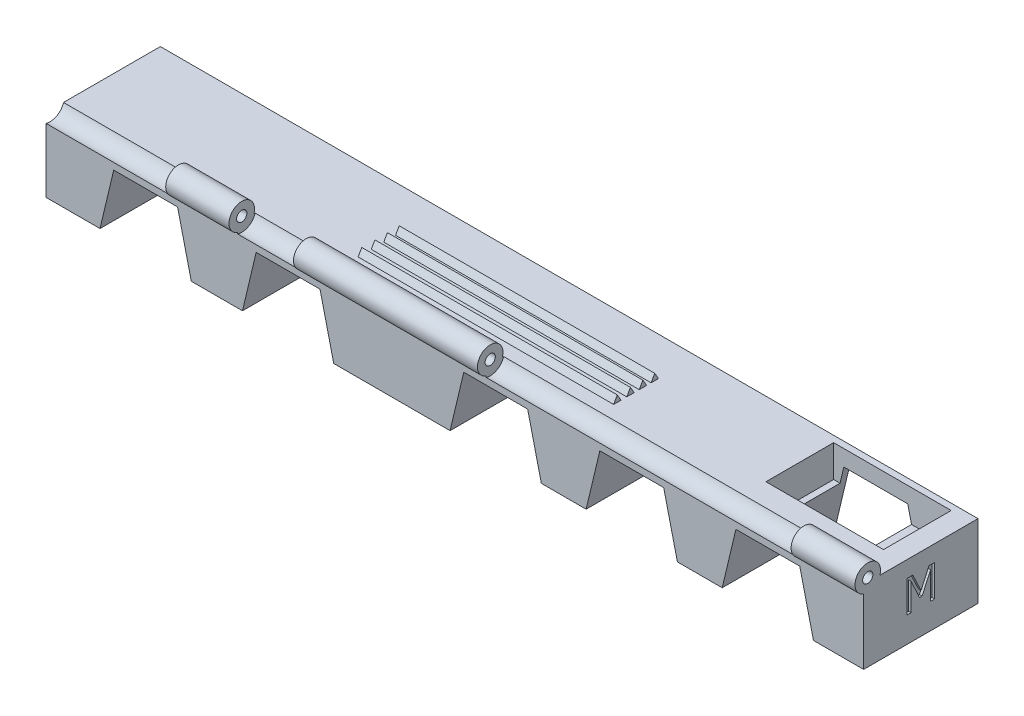
from build123d import *

# Parameters (mm, degrees)
SKETCH1_R                 = 7.62
BOSS_EXTRUDE3_DEPTH       = 127
CUT_EXTRUDE8_DEPTH        = 10.16
CUT_EXTRUDE8_DEPTH_BACK   = 20.828
SKETCH3_W                 = 3.81
SKETCH3_H                 = 18.722382306
SKETCH3_W_2               = 12.7
SKETCH5_W                 = 3.81
SKETCH5_H                 = 18.722382306
CUT_EXTRUDE9_DEPTH        = 36.576
SKETCH6_W                 = 12.7
SKETCH6_H                 = 18.722382306
SKETCH6_W_2               = 3.81
SKETCH6_W_3               = 71.12
CUT_EXTRUDE11_DEPTH       = 36.576
CUT_EXTRUDE12_DEPTH       = 20.32
CUT_EXTRUDE12_DEPTH_BACK  = 33.02
CUT_EXTRUDE21_DEPTH       = 20.32
CUT_EXTRUDE21_DEPTH_BACK  = 33.02
CUT_EXTRUDE23_DEPTH       = 20.32
CUT_EXTRUDE23_DEPTH_BACK  = 33.02
CUT_EXTRUDE26_DEPTH       = 20.32
CUT_EXTRUDE26_DEPTH_BACK  = 33.02
CUT_EXTRUDE27_DEPTH       = 20.32
CUT_EXTRUDE27_DEPTH_BACK  = 33.02
SCALE1_SCALE              = 1.3
CUT_EXTRUDE28_START       = -154.94
SKETCH26_R                = 13.065490037
CUT_EXTRUDE28_DEPTH       = 154.94
SKETCH27_W                = 13.208
SKETCH27_H                = 4.731500073
BOSS_EXTRUDE4_DEPTH       = 165.1
CUT_EXTRUDE29_DEPTH       = 14.224
CUT_EXTRUDE29_DEPTH_BACK  = 203.962
SKETCH28_W                = 13.208
SKETCH28_H                = 4.731500073
SKETCH29_W                = 150.317302473
SKETCH29_H                = 24.765
BOSS_EXTRUDE5_DEPTH       = 33.02
SKETCH30_W                = 165.1
SKETCH30_H                = 8.255
CUT_EXTRUDE30_DEPTH       = 33.02
SKETCH31_W                = 13.97
SKETCH31_H                = 16.51
CUT_EXTRUDE31_DEPTH       = 204.216
CUT_EXTRUDE32_DEPTH       = 204.216
CUT_EXTRUDE33_DEPTH       = 204.216
BOSS_EXTRUDE6_DEPTH       = 19.05
BOSS_EXTRUDE7_DEPTH       = 165.1
CUT_EXTRUDE34_DEPTH       = 165.1
CUT_EXTRUDE45_DEPTH       = 19.558
CUT_EXTRUDE45_DEPTH_BACK  = 50.8
SKETCH46_R                = 6.3627
CUT_EXTRUDE46_DEPTH       = 55.88
CUT_EXTRUDE46_DEPTH_BACK  = 50.8
SKETCH47_R                = 6.3627
CUT_EXTRUDE47_DEPTH       = 11.43
CUT_EXTRUDE47_DEPTH_BACK  = 67.818
CUT_EXTRUDE48_DEPTH       = 9.652
CUT_EXTRUDE48_DEPTH_BACK  = 67.31
SKETCH50_R                = 3.9878
SKETCH51_W                = 2.128397358
SKETCH51_H                = 21.339200712
CUT_EXTRUDE49_DEPTH       = 67.31
SKETCH52_R                = 6.604
CUT_EXTRUDE50_DEPTH       = 50.8
CUT_EXTRUDE51_START       = -50.8
SKETCH53_R                = 6.604
CUT_EXTRUDE51_DEPTH       = 50.8
BOSS_EXTRUDE8_DEPTH       = 19.05
CUT_EXTRUDE52_DEPTH       = 19.05
BOSS_EXTRUDE9_DEPTH       = 19.05
CUT_EXTRUDE53_DEPTH       = 19.05
SKETCH58_W                = 0.5461
SKETCH58_H                = 19.05
CUT_EXTRUDE54_DEPTH       = 45.974
CUT_EXTRUDE55_DEPTH       = 45.974
BOSS_EXTRUDE10_DEPTH      = 19.05
SKETCH61_W                = 0.3429
SKETCH61_H                = 19.05
CUT_EXTRUDE56_DEPTH       = 37.338
CUT_EXTRUDE60_DEPTH       = 8.89
CUT_EXTRUDE60_DEPTH_BACK  = 38.1
SKETCH75_R                = 3.175
CUT_EXTRUDE61_DEPTH       = 12.7
CUT_EXTRUDE61_DEPTH_BACK  = 67.31
SKETCH81_R                = 2.499995
BOSS_EXTRUDE11_DEPTH      = 9.398
BOSS_EXTRUDE12_START      = -9.398
BOSS_EXTRUDE12_DEPTH      = 9.398
CUT_EXTRUDE62_DEPTH       = 5.842
CUT_EXTRUDE62_DEPTH_BACK  = 24.892
BOSS_EXTRUDE13_DEPTH      = 19.05
CUT_EXTRUDE64_DEPTH       = 19.05
BOSS_EXTRUDE15_DEPTH      = 19.05
CUT_EXTRUDE65_DEPTH       = 19.05
BOSS_EXTRUDE16_DEPTH      = 19.05
CUT_EXTRUDE66_DEPTH       = 19.05
BOSS_EXTRUDE17_DEPTH      = 19.05
CUT_EXTRUDE67_DEPTH       = 19.05
BOSS_EXTRUDE18_DEPTH      = 19.05
CUT_EXTRUDE68_DEPTH       = 19.05
BOSS_EXTRUDE19_DEPTH      = 19.05
CUT_EXTRUDE69_DEPTH       = 19.05
BOSS_EXTRUDE20_DEPTH      = 19.05
CUT_EXTRUDE70_DEPTH       = 19.05
BOSS_EXTRUDE21_DEPTH      = 19.05
CUT_EXTRUDE71_DEPTH       = 10.668
CUT_EXTRUDE71_DEPTH_BACK  = 35.306
SKETCH105_R               = 2.50000008
CUT_EXTRUDE72_DEPTH       = 19.812
CUT_EXTRUDE72_DEPTH_BACK  = 56.388
SKETCH106_W               = 0.381
SKETCH106_H               = 30.850817133
SKETCH108_W               = 19.05
SKETCH108_H               = 3.81
BOSS_EXTRUDE22_DEPTH      = 162.56
SKETCH109_W               = 19.05
SKETCH109_H               = 40.733446347
CUT_EXTRUDE73_DEPTH       = 162.56
SKETCH110_R               = 3.425685186
SKETCH110_R_2             = 3.853308442
BOSS_EXTRUDE23_DEPTH      = 19.05
SKETCH111_W               = 162.56
SKETCH111_H               = 2.54
CUT_EXTRUDE76_DEPTH       = 19.05
SKETCH112_R               = 1.6002
SKETCH112_R_2             = 0.8128
BOSS_EXTRUDE25_DEPTH      = 162.56
CUT_EXTRUDE83_DEPTH       = 19.558
CUT_EXTRUDE83_DEPTH_BACK  = 29.21
SKETCH115_W               = 55.88
SKETCH115_H               = 2.413
SKETCH118_W               = 55.88
SKETCH118_H               = 0.565603497
CUT_EXTRUDE84_DEPTH       = 29.21
SKETCH119_R               = 1.778
CUT_EXTRUDE85_DEPTH       = 57.912
CUT_EXTRUDE86_START       = 65.278
SKETCH120_R               = 1.778
CUT_EXTRUDE86_DEPTH       = 65.278
BOSS_EXTRUDE26_DEPTH      = 3.6817427
SKETCH124_W               = 0.0012573
SKETCH124_H               = 16.51
BOSS_EXTRUDE27_DEPTH      = 162.56
CUT_EXTRUDE87_DEPTH       = 162.56
BOSS_EXTRUDE29_DEPTH      = 50.8
FILLET5_R                 = 0.762
SKETCH131_W               = 0.398403583
SKETCH131_H               = 0.613592462
CUT_EXTRUDE88_DEPTH       = 50.8
BOSS_EXTRUDE30_DEPTH      = 50.8
SKETCH133_W               = 0.963005867
SKETCH133_H               = 0.762
CUT_EXTRUDE89_DEPTH       = 50.8
BOSS_EXTRUDE31_DEPTH      = 50.8
BOSS_EXTRUDE33_DEPTH      = 50.8
BOSS_EXTRUDE34_DEPTH      = 50.8
BOSS_EXTRUDE36_DEPTH      = 50.8
BOSS_EXTRUDE38_DEPTH      = 50.8
CUT_EXTRUDE90_DEPTH       = 50.8
BOSS_EXTRUDE40_DEPTH      = 50.8
CUT_EXTRUDE91_DEPTH       = 50.8
BOSS_EXTRUDE41_DEPTH      = 50.8
CUT_EXTRUDE92_DEPTH       = 50.8
CUT_EXTRUDE93_DEPTH       = 50.8
CUT_EXTRUDE94_DEPTH       = 50.8
BOSS_EXTRUDE42_DEPTH      = 50.8
CUT_EXTRUDE95_DEPTH       = 50.8
BOSS_EXTRUDE43_DEPTH      = 50.8
CUT_EXTRUDE96_DEPTH       = 50.8
SKETCH150_R               = 2.54
BOSS_EXTRUDE44_DEPTH      = 50.8
SKETCH151_R               = 1.27
CUT_EXTRUDE97_DEPTH       = 50.8
SKETCH152_R               = 2.794
CUT_EXTRUDE98_DEPTH       = 68.326
CUT_EXTRUDE99_START       = 58.928
SKETCH153_R               = 2.794
CUT_EXTRUDE99_DEPTH       = 58.928
SKETCH157_W               = 5.08
SKETCH157_H               = 12.7
CUT_EXTRUDE100_DEPTH      = 5.08
SKETCH158_R               = 1.7827949
SKETCH158_R_2             = 1.016
BOSS_EXTRUDE45_DEPTH      = 50.8
SKETCH159_W               = 162.56
SKETCH159_H               = 1.905
CUT_EXTRUDE101_DEPTH      = 29.21
BOSS_EXTRUDE47_DEPTH      = 55.88
BOSS_EXTRUDE47_DEPTH_BACK = 106.68
SKETCH162_R               = 1.016
SKETCH165_R               = 2.794
CUT_EXTRUDE104_DEPTH      = 25.527
SKETCH167_R               = 2.794
CUT_EXTRUDE105_DEPTH      = 12.827
CUT_EXTRUDE106_START      = -62.357
SKETCH171_R               = 2.794
CUT_EXTRUDE106_DEPTH      = 62.357
CUT_EXTRUDE108_DEPTH      = 6.35
BOSS_EXTRUDE48_DEPTH      = 13.462
CUT_EXTRUDE109_DEPTH      = 13.462
SKETCH177_W               = 7.62
SKETCH177_H               = 13.433519273
CUT_EXTRUDE110_DEPTH      = 6.35
SKETCH178_W               = 8.89
SKETCH178_H               = 14.703519273
BOSS_EXTRUDE50_DEPTH      = 7.366
SKETCH181_W               = 0.762
SKETCH181_H               = 13.433519273
CUT_EXTRUDE113_DEPTH      = 19.558
SKETCH183_W               = 8.382
SKETCH183_H               = 13.462
CUT_EXTRUDE115_DEPTH      = 6.35
CUT_EXTRUDE116_DEPTH      = 0.508
CUT_EXTRUDE117_DEPTH      = 0.508
SKETCH187_W               = 23.368
SKETCH187_H               = 13.462
CUT_EXTRUDE119_DEPTH      = 6.35


with BuildPart() as part:
    # Sketch1 → Boss-Extrude3 (new body)
    with BuildSketch(Plane(origin=(0, 0, 0), x_dir=(0, 0, -1), z_dir=(1, 0, 0))):
        with BuildLine():
            Line((0, 19.05), (0, 0))
            Line((0, 0), (25.4, 0))
            Line((25.4, 0), (25.4, 19.05))
            Line((25.4, 19.05), (17.78, 19.05))
            Line((17.78, 19.05), (17.78, 22.689615441))
            ThreePointArc((17.78, 22.689615441), (12.7, 41.411997747), (7.62, 22.689615441))
            Line((7.62, 22.689615441), (7.62, 19.05))
            Line((7.62, 19.05), (0, 19.05))
        make_face()
        with Locations((12.7, 31.361620795)):
            Circle(SKETCH1_R, mode=Mode.SUBTRACT)
    extrude(amount=BOSS_EXTRUDE3_DEPTH)

    # Sketch3 → Cut-Extrude8 (cut, two sides: drawn at the far end of the back side and taken through both)
    with BuildSketch(Plane.XY.offset(-7.62).offset(-CUT_EXTRUDE8_DEPTH_BACK)):
        with Locations((17.145, 32.050806594)):
            Rectangle(SKETCH3_W, SKETCH3_H)
        with Locations((6.35, 32.050806594)):
            Rectangle(SKETCH3_W_2, SKETCH3_H)
    extrude(amount=CUT_EXTRUDE8_DEPTH + CUT_EXTRUDE8_DEPTH_BACK, mode=Mode.SUBTRACT)

    # Sketch5 → Cut-Extrude9 (cut)
    with BuildSketch(Plane.XY):
        with Locations((23.495, 32.050806594)):
            Rectangle(SKETCH5_W, SKETCH5_H)
    extrude(amount=-CUT_EXTRUDE9_DEPTH, mode=Mode.SUBTRACT)

    # Sketch6 → Cut-Extrude11 (cut)
    with BuildSketch(Plane.XY):
        with Locations((120.65, 32.050806594)):
            Rectangle(SKETCH6_W, SKETCH6_H)
        with Locations((109.855, 32.050806594)):
            Rectangle(SKETCH6_W_2, SKETCH6_H)
        with Locations((103.505, 32.050806594)):
            Rectangle(SKETCH6_W_2, SKETCH6_H)
        with Locations((63.5, 32.050806594)):
            Rectangle(SKETCH6_W_3, SKETCH6_H)
    extrude(amount=-CUT_EXTRUDE11_DEPTH, mode=Mode.SUBTRACT)

    # Sketch7 → Cut-Extrude12 (cut, two sides: drawn at the far end of the back side and taken through both)
    with BuildSketch(Plane(origin=(0, 0, -17.78), x_dir=(-1, 0, 0), z_dir=(0, 0, -1)).offset(-CUT_EXTRUDE12_DEPTH_BACK)):
        Polygon((-116.586, 0), (-113.807281861, 15.758893664), (-108.211772717, 15.758893664), (-105.54672105, 0), align=None)
    extrude(amount=CUT_EXTRUDE12_DEPTH + CUT_EXTRUDE12_DEPTH_BACK, mode=Mode.SUBTRACT)

    # Sketch17 → Cut-Extrude21 (cut, two sides: drawn at the far end of the back side and taken through both)
    with BuildSketch(Plane.XY.offset(-CUT_EXTRUDE21_DEPTH_BACK)):
        Polygon((85.106525364, -0.117469901), (87.885243503, 15.641423763), (93.480752647, 15.641423763), (96.145804314, -0.117469901), align=None)
    extrude(amount=CUT_EXTRUDE21_DEPTH + CUT_EXTRUDE21_DEPTH_BACK, mode=Mode.SUBTRACT)

    # Sketch19 → Cut-Extrude23 (cut, two sides: drawn at the far end of the back side and taken through both)
    with BuildSketch(Plane.XY.offset(-CUT_EXTRUDE23_DEPTH_BACK)):
        Polygon((64.184734764, -0.117469901), (66.963452903, 15.641423763), (72.558962046, 15.641423763), (75.224013714, -0.117469901), align=None)
    extrude(amount=CUT_EXTRUDE23_DEPTH + CUT_EXTRUDE23_DEPTH_BACK, mode=Mode.SUBTRACT)

    # Sketch22 → Cut-Extrude26 (cut, two sides: drawn at the far end of the back side and taken through both)
    with BuildSketch(Plane.XY.offset(-CUT_EXTRUDE26_DEPTH_BACK)):
        Polygon((32.802048863, -0.117469901), (35.580767002, 15.641423763), (41.176276145, 15.641423763), (43.841327813, -0.117469901), align=None)
    extrude(amount=CUT_EXTRUDE26_DEPTH + CUT_EXTRUDE26_DEPTH_BACK, mode=Mode.SUBTRACT)

    # Sketch23 → Cut-Extrude27 (cut, two sides: drawn at the far end of the back side and taken through both)
    with BuildSketch(Plane.XY.offset(-CUT_EXTRUDE27_DEPTH_BACK)):
        Polygon((11.350592677, -0.117469901), (14.129310816, 15.641423763), (19.72481996, 15.641423763), (22.389871627, -0.117469901), align=None)
    extrude(amount=CUT_EXTRUDE27_DEPTH + CUT_EXTRUDE27_DEPTH_BACK, mode=Mode.SUBTRACT)


with BuildPart() as part_1:
    # Scale1: scaled about (62.883509837, 12.209293534, -12.7)
    add(part.part.scale(SCALE1_SCALE).moved(Location((-18.865052951, -3.66278806, 3.81))))

    # Sketch26 → Cut-Extrude28 (cut)
    with BuildSketch(Plane(origin=(129.724947049, 0, 0), x_dir=(0, 0, -1), z_dir=(1, 0, 0)).offset(CUT_EXTRUDE28_START)):
        with Locations((12.7, 37.107318973)):
            Circle(SKETCH26_R)
    extrude(amount=CUT_EXTRUDE28_DEPTH, mode=Mode.SUBTRACT)

    # Sketch27 → Boss-Extrude4 (add)
    with BuildSketch(Plane(origin=(146.234947049, 0, 0), x_dir=(0, 0, -1), z_dir=(1, 0, 0))):
        with Locations((12.7, 23.467961976)):
            Rectangle(SKETCH27_W, SKETCH27_H)
    extrude(amount=-BOSS_EXTRUDE4_DEPTH)

    # Sketch28 → Cut-Extrude29 (cut, two sides: drawn at the far end of the back side and taken through both)
    with BuildSketch(Plane.ZY.offset(18.865052951).offset(-CUT_EXTRUDE29_DEPTH_BACK)):
        with Locations((-12.7, 23.467961976)):
            Rectangle(SKETCH28_W, SKETCH28_H)
    extrude(amount=CUT_EXTRUDE29_DEPTH + CUT_EXTRUDE29_DEPTH_BACK, mode=Mode.SUBTRACT)

    # Sketch29 → Boss-Extrude5 (add)
    with BuildSketch(Plane.XY.offset(3.81)):
        with Locations((71.076295812, 8.71971194)):
            Rectangle(SKETCH29_W, SKETCH29_H)
    extrude(amount=-BOSS_EXTRUDE5_DEPTH)

    # Sketch30 → Cut-Extrude30 (cut)
    with BuildSketch(Plane(origin=(0, 0, -29.21), x_dir=(-1, 0, 0), z_dir=(0, 0, -1))):
        with Locations((-63.684947049, 16.97471194)):
            Rectangle(SKETCH30_W, SKETCH30_H)
    extrude(amount=-CUT_EXTRUDE30_DEPTH, mode=Mode.SUBTRACT)

    # Sketch31 → Cut-Extrude31 (cut)
    with BuildSketch(Plane.ZY.offset(18.865052951)):
        with Locations((-3.175, 4.59221194)):
            Rectangle(SKETCH31_W, SKETCH31_H)
    extrude(amount=-CUT_EXTRUDE31_DEPTH, mode=Mode.SUBTRACT)

    # Sketch33 → Cut-Extrude32 (cut)
    with BuildSketch(Plane(origin=(0, 0, -29.21), x_dir=(-1, 0, 0), z_dir=(0, 0, -1))):
        Polygon((-104.959947049, 9.67221194), (-108.134947049, -3.66278806), (-89.084947049, -3.66278806), (-92.259947049, 9.67221194), align=None)
        Polygon((-6.534947049, 9.67221194), (-9.709947049, -3.66278806), (9.340052951, -3.66278806), (6.165052951, 9.67221194), align=None)
        Polygon((-35.109947049, 9.67221194), (-38.284947049, -3.66278806), (-19.234947049, -3.66278806), (-22.409947049, 9.67221194), align=None)
        Polygon((-76.384947049, 9.67221194), (-79.559947049, -3.66278806), (-60.509947049, -3.66278806), (-63.684947049, 9.67221194), align=None)
    extrude(amount=-CUT_EXTRUDE32_DEPTH, mode=Mode.SUBTRACT)

    # Sketch34 → Cut-Extrude33 (cut)
    with BuildSketch(Plane.XY.offset(-10.16)):
        Polygon((136.709947049, -3.66278806), (133.534947049, 9.67221194), (120.834947049, 9.67221194), (117.659947049, -3.66278806), align=None)
    extrude(amount=-CUT_EXTRUDE33_DEPTH, mode=Mode.SUBTRACT)

    # Sketch35 → Boss-Extrude6 (add)
    with BuildSketch(Plane.XY.offset(-10.16)):
        Polygon((-18.865052951, 12.84721194), (-18.865052951, 15.38721194), (146.276628632, 15.38721194), (146.234947049, 12.84721194), align=None)
    extrude(amount=-BOSS_EXTRUDE6_DEPTH)

    # Sketch44 → Boss-Extrude7 (add)
    with BuildSketch(Plane(origin=(146.234947049, 0, 0), x_dir=(0, 0, -1), z_dir=(1, 0, 0))):
        with BuildLine():
            ThreePointArc((26.035, 19.19721194), (17.676953686, 25.221350882), (14.605, 15.38721194))
            Line((14.605, 15.38721194), (24.765, 15.38721194))
            ThreePointArc((24.765, 15.38721194), (25.709138943, 17.189165625), (26.035, 19.19721194))
        make_face()
    extrude(amount=-BOSS_EXTRUDE7_DEPTH)

    # Sketch45 → Cut-Extrude34 (cut)
    with BuildSketch(Plane(origin=(146.234947049, 0, 0), x_dir=(0, 0, -1), z_dir=(1, 0, 0))):
        with BuildLine():
            ThreePointArc((19.685, 15.38721194), (22.379076836, 16.503135103), (23.495, 19.19721194))
            ThreePointArc((23.495, 19.19721194), (16.990923164, 21.891288776), (19.685, 15.38721194))
        make_face()
    extrude(amount=-CUT_EXTRUDE34_DEPTH, mode=Mode.SUBTRACT)

    # Sketch46 → Cut-Extrude45 (cut, two sides: drawn at the far end of the back side and taken through both)
    with BuildSketch(Plane(origin=(146.234947049, 0, 0), x_dir=(0, 0, -1), z_dir=(1, 0, 0)).offset(-CUT_EXTRUDE45_DEPTH_BACK)):
        with Locations((19.685, 19.19721194)):
            Circle(SKETCH46_R)
    extrude(amount=CUT_EXTRUDE45_DEPTH + CUT_EXTRUDE45_DEPTH_BACK, mode=Mode.SUBTRACT)

    # Sketch47 → Cut-Extrude46 (cut, two sides: drawn at the far end of the back side and taken through both)
    with BuildSketch(Plane.ZY.offset(18.865052951).offset(-CUT_EXTRUDE46_DEPTH_BACK)):
        with Locations((-19.685, 19.19721194)):
            Circle(SKETCH47_R)
    extrude(amount=CUT_EXTRUDE46_DEPTH + CUT_EXTRUDE46_DEPTH_BACK, mode=Mode.SUBTRACT)

    # Sketch49 → Cut-Extrude47 (cut, two sides: drawn at the far end of the back side and taken through both)
    with BuildSketch(Plane(origin=(95.434947049, 0, 0), x_dir=(0, 0, -1), z_dir=(1, 0, 0)).offset(-CUT_EXTRUDE47_DEPTH_BACK)):
        with BuildLine():
            ThreePointArc((26.035, 19.19721194), (17.676953686, 25.221350882), (14.605, 15.38721194))
            Line((14.605, 15.38721194), (14.764671861, 15.38721194))
            ThreePointArc((14.764671861, 15.38721194), (17.671728162, 25.085544939), (25.908, 19.19721194))
            ThreePointArc((25.908, 19.19721194), (25.573332999, 17.183940102), (24.605328139, 15.38721194))
            Line((24.605328139, 15.38721194), (24.765, 15.38721194))
            ThreePointArc((24.765, 15.38721194), (25.709138943, 17.189165625), (26.035, 19.19721194))
        make_face()
    extrude(amount=CUT_EXTRUDE47_DEPTH + CUT_EXTRUDE47_DEPTH_BACK, mode=Mode.SUBTRACT)

    # Sketch50 → Cut-Extrude48 (cut, two sides: drawn at the far end of the back side and taken through both)
    with BuildSketch(Plane(origin=(95.434947049, 0, 0), x_dir=(0, 0, -1), z_dir=(1, 0, 0)).offset(-CUT_EXTRUDE48_DEPTH_BACK)):
        with Locations((19.685, 19.19721194)):
            Circle(SKETCH50_R)
    extrude(amount=CUT_EXTRUDE48_DEPTH + CUT_EXTRUDE48_DEPTH_BACK, mode=Mode.SUBTRACT)

    # Sketch51 → Cut-Extrude49 (cut)
    with BuildSketch(Plane(origin=(0, 0, -29.21), x_dir=(-1, 0, 0), z_dir=(0, 0, -1))):
        with Locations((-147.299145728, 7.006812296)):
            Rectangle(SKETCH51_W, SKETCH51_H)
    extrude(amount=-CUT_EXTRUDE49_DEPTH, mode=Mode.SUBTRACT)

    # Sketch52 → Cut-Extrude50 (cut)
    with BuildSketch(Plane(origin=(146.234947049, 0, 0), x_dir=(0, 0, -1), z_dir=(1, 0, 0))):
        with Locations((19.685, 19.19721194)):
            Circle(SKETCH52_R)
    extrude(amount=-CUT_EXTRUDE50_DEPTH, mode=Mode.SUBTRACT)

    # Sketch53 → Cut-Extrude51 (cut)
    with BuildSketch(Plane.ZY.offset(18.865052951).offset(CUT_EXTRUDE51_START)):
        with Locations((-19.685, 19.19721194)):
            Circle(SKETCH53_R)
    extrude(amount=CUT_EXTRUDE51_DEPTH, mode=Mode.SUBTRACT)

    # Sketch54 → Boss-Extrude8 (add)
    with BuildSketch(Plane.XY.offset(-10.16)):
        Polygon((-9.340052951, -3.66278806), (-7.752552951, -3.66278806), (-4.577552951, 9.67221194), (-6.165052951, 9.67221194), align=None)
    extrude(amount=-BOSS_EXTRUDE8_DEPTH)

    # Sketch55 → Cut-Extrude52 (cut)
    with BuildSketch(Plane.XY.offset(-10.16)):
        Polygon((8.122447049, 9.67221194), (6.534947049, 9.67221194), (9.709947049, -3.66278806), (11.297447049, -3.66278806), align=None)
    extrude(amount=-CUT_EXTRUDE52_DEPTH, mode=Mode.SUBTRACT)

    # Sketch56 → Boss-Extrude9 (add)
    with BuildSketch(Plane.XY.offset(-10.16)):
        Polygon((19.234947049, -3.66278806), (20.822447049, -3.66278806), (23.997447049, 9.67221194), (22.409947049, 9.67221194), align=None)
        Polygon((60.509947049, -3.66278806), (62.097447049, -3.66278806), (65.272447049, 9.67221194), (63.684947049, 9.67221194), align=None)
        Polygon((136.709947049, -3.66278806), (135.122447049, -3.66278806), (131.947447049, 9.67221194), (133.534947049, 9.67221194), align=None)
    extrude(amount=-BOSS_EXTRUDE9_DEPTH)

    # Sketch57 → Cut-Extrude53 (cut)
    with BuildSketch(Plane.XY.offset(-10.16)):
        Polygon((35.109947049, 9.67221194), (36.697447049, 9.67221194), (39.872447049, -3.66278806), (38.284947049, -3.66278806), align=None)
        Polygon((79.559947049, -3.66278806), (81.147447049, -3.66278806), (77.972447049, 9.67221194), (76.384947049, 9.67221194), align=None)
        Polygon((117.659947049, -3.66278806), (116.072447049, -3.66278806), (119.247447049, 9.67221194), (120.834947049, 9.67221194), align=None)
    extrude(amount=-CUT_EXTRUDE53_DEPTH, mode=Mode.SUBTRACT)

    # Sketch58 → Cut-Extrude54 (cut)
    with BuildSketch(Plane(origin=(0, 0, -29.21), x_dir=(-1, 0, 0), z_dir=(0, 0, -1))):
        with Locations((18.592002951, 5.86221194)):
            Rectangle(SKETCH58_W, SKETCH58_H)
        with Locations((-145.961897049, 5.86221194)):
            Rectangle(SKETCH58_W, SKETCH58_H)
    extrude(amount=-CUT_EXTRUDE54_DEPTH, mode=Mode.SUBTRACT)

    # Sketch59 → Cut-Extrude55 (cut)
    with BuildSketch(Plane.XY.offset(-10.16)):
        Polygon((-7.752552951, -3.66278806), (-8.324052951, -3.66278806), (-5.149052951, 9.67221194), (-4.577552951, 9.67221194), align=None)
        Polygon((23.997447049, 9.67221194), (23.425947049, 9.67221194), (20.250947049, -3.66278806), (20.822447049, -3.66278806), align=None)
        Polygon((62.097447049, -3.66278806), (61.525947049, -3.66278806), (64.700947049, 9.67221194), (65.272447049, 9.67221194), align=None)
        Polygon((135.122447049, -3.66278806), (135.693947049, -3.66278806), (132.518947049, 9.67221194), (131.947447049, 9.67221194), align=None)
    extrude(amount=-CUT_EXTRUDE55_DEPTH, mode=Mode.SUBTRACT)

    # Sketch60 → Boss-Extrude10 (add)
    with BuildSketch(Plane.XY.offset(-10.16)):
        Polygon((8.122447049, 9.67221194), (7.550947049, 9.67221194), (10.725947049, -3.66278806), (11.297447049, -3.66278806), align=None)
        Polygon((36.697447049, 9.67221194), (36.125947049, 9.67221194), (39.300947049, -3.66278806), (39.872447049, -3.66278806), align=None)
        Polygon((77.972447049, 9.67221194), (77.400947049, 9.67221194), (80.575947049, -3.66278806), (81.147447049, -3.66278806), align=None)
        Polygon((116.072447049, -3.66278806), (116.643947049, -3.66278806), (119.818947049, 9.67221194), (119.247447049, 9.67221194), align=None)
    extrude(amount=-BOSS_EXTRUDE10_DEPTH)

    # Sketch61 → Cut-Extrude56 (cut)
    with BuildSketch(Plane.XY.offset(-10.16)):
        with Locations((145.517397049, 5.86221194)):
            Rectangle(SKETCH61_W, SKETCH61_H)
        with Locations((-18.147502951, 5.86221194)):
            Rectangle(SKETCH61_W, SKETCH61_H)
    extrude(amount=-CUT_EXTRUDE56_DEPTH, mode=Mode.SUBTRACT)

    # Sketch75 → Cut-Extrude60 (cut, two sides: drawn at the far end of the back side and taken through both)
    with BuildSketch(Plane(origin=(0, -3.66278806, 0), x_dir=(-1, 0, 0), z_dir=(0, -1, 0)).offset(-CUT_EXTRUDE60_DEPTH_BACK)):
        with Locations((13.043301181, 19.685)):
            Circle(SKETCH75_R)
    extrude(amount=CUT_EXTRUDE60_DEPTH + CUT_EXTRUDE60_DEPTH_BACK, mode=Mode.SUBTRACT)

    # Sketch81 → Cut-Extrude61 (cut, two sides: drawn at the far end of the back side and taken through both)
    with BuildSketch(Plane(origin=(0, -3.66278806, 0), x_dir=(-1, 0, 0), z_dir=(0, -1, 0)).offset(-CUT_EXTRUDE61_DEPTH_BACK)):
        with Locations((13.043301181, 19.685)):
            Circle(SKETCH81_R)
        with Locations((-140.413195279, 19.685)):
            Circle(SKETCH81_R)
    extrude(amount=CUT_EXTRUDE61_DEPTH + CUT_EXTRUDE61_DEPTH_BACK, mode=Mode.SUBTRACT)

    # Sketch85 → Boss-Extrude11 (add)
    with BuildSketch(Plane(origin=(145.345947049, 0, 0), x_dir=(0, 0, -1), z_dir=(1, 0, 0))):
        with BuildLine():
            Line((14.290862812, 15.38721194), (10.16, 15.38721194))
            Line((10.16, 15.38721194), (10.16, -3.66278806))
            Line((10.16, -3.66278806), (29.21, -3.66278806))
            Line((29.21, -3.66278806), (29.21, 15.38721194))
            Line((29.21, 15.38721194), (25.079137188, 15.38721194))
            ThreePointArc((25.079137188, 15.38721194), (19.685, 12.59321194), (14.290862812, 15.38721194))
        make_face()
    extrude(amount=-BOSS_EXTRUDE11_DEPTH)

    # Sketch86 → Boss-Extrude12 (add)
    with BuildSketch(Plane.ZY.offset(17.976052951).offset(BOSS_EXTRUDE12_START)):
        with BuildLine():
            Line((-25.079137188, 15.38721194), (-29.21, 15.38721194))
            Line((-29.21, 15.38721194), (-29.21, -3.66278806))
            Line((-29.21, -3.66278806), (-10.16, -3.66278806))
            Line((-10.16, -3.66278806), (-10.16, 15.38721194))
            Line((-10.16, 15.38721194), (-14.290862812, 15.38721194))
            ThreePointArc((-14.290862812, 15.38721194), (-19.685, 12.59321194), (-25.079137188, 15.38721194))
        make_face()
    extrude(amount=BOSS_EXTRUDE12_DEPTH)

    # Sketch87 → Cut-Extrude62 (cut, two sides: drawn at the far end of the back side and taken through both)
    with BuildSketch(Plane.XY.offset(-10.16).offset(-CUT_EXTRUDE62_DEPTH_BACK)):
        Polygon((116.643947049, -3.66278806), (119.818947049, 9.67221194), (119.564947049, 9.67221194), (116.389947049, -3.66278806), align=None)
    extrude(amount=CUT_EXTRUDE62_DEPTH + CUT_EXTRUDE62_DEPTH_BACK, mode=Mode.SUBTRACT)

    # Sketch88 → Boss-Extrude13 (add)
    with BuildSketch(Plane.XY.offset(-10.16)):
        Polygon((135.693947049, -3.66278806), (132.518947049, 9.67221194), (132.264947049, 9.67221194), (135.439947049, -3.66278806), align=None)
    extrude(amount=-BOSS_EXTRUDE13_DEPTH)

    # Sketch89 → Cut-Extrude64 (cut)
    with BuildSketch(Plane.XY.offset(-10.16)):
        Polygon((77.400947049, 9.67221194), (80.575947049, -3.66278806), (80.829947049, -3.66278806), (77.654947049, 9.67221194), align=None)
    extrude(amount=-CUT_EXTRUDE64_DEPTH, mode=Mode.SUBTRACT)

    # Sketch91 → Boss-Extrude15 (add)
    with BuildSketch(Plane.XY.offset(-10.16)):
        Polygon((61.525947049, -3.66278806), (64.700947049, 9.67221194), (64.954947049, 9.67221194), (61.779947049, -3.66278806), align=None)
    extrude(amount=-BOSS_EXTRUDE15_DEPTH)

    # Sketch92 → Cut-Extrude65 (cut)
    with BuildSketch(Plane.XY.offset(-10.16)):
        Polygon((80.829947049, -3.66278806), (81.083947049, -3.66278806), (77.908947049, 9.67221194), (77.654947049, 9.67221194), align=None)
    extrude(amount=-CUT_EXTRUDE65_DEPTH, mode=Mode.SUBTRACT)

    # Sketch93 → Boss-Extrude16 (add)
    with BuildSketch(Plane.XY.offset(-10.16)):
        Polygon((64.954947049, 9.67221194), (61.779947049, -3.66278806), (62.033947049, -3.66278806), (65.208947049, 9.67221194), align=None)
    extrude(amount=-BOSS_EXTRUDE16_DEPTH)

    # Sketch94 → Cut-Extrude66 (cut)
    with BuildSketch(Plane.XY.offset(-10.16)):
        Polygon((108.134947049, -3.66278806), (104.959947049, 9.67221194), (105.213947049, 9.67221194), (108.388947049, -3.66278806), align=None)
    extrude(amount=-CUT_EXTRUDE66_DEPTH, mode=Mode.SUBTRACT)

    # Sketch95 → Boss-Extrude17 (add)
    with BuildSketch(Plane.XY.offset(-10.16)):
        Polygon((92.259947049, 9.67221194), (92.513947049, 9.67221194), (89.338947049, -3.66278806), (89.084947049, -3.66278806), align=None)
    extrude(amount=-BOSS_EXTRUDE17_DEPTH)

    # Sketch96 → Cut-Extrude67 (cut)
    with BuildSketch(Plane.XY.offset(-10.16)):
        Polygon((81.083947049, -3.66278806), (81.337947049, -3.66278806), (78.162947049, 9.67221194), (77.908947049, 9.67221194), align=None)
    extrude(amount=-CUT_EXTRUDE67_DEPTH, mode=Mode.SUBTRACT)

    # Sketch97 → Boss-Extrude18 (add)
    with BuildSketch(Plane.XY.offset(-10.16)):
        Polygon((62.033947049, -3.66278806), (65.208947049, 9.67221194), (65.462947049, 9.67221194), (62.287947049, -3.66278806), align=None)
    extrude(amount=-BOSS_EXTRUDE18_DEPTH)

    # Sketch98 → Cut-Extrude68 (cut)
    with BuildSketch(Plane.XY.offset(-10.16)):
        Polygon((39.300947049, -3.66278806), (39.808947049, -3.66278806), (36.633947049, 9.67221194), (36.125947049, 9.67221194), align=None)
    extrude(amount=-CUT_EXTRUDE68_DEPTH, mode=Mode.SUBTRACT)

    # Sketch99 → Boss-Extrude19 (add)
    with BuildSketch(Plane.XY.offset(-10.16)):
        Polygon((20.250947049, -3.66278806), (20.758947049, -3.66278806), (23.933947049, 9.67221194), (23.425947049, 9.67221194), align=None)
    extrude(amount=-BOSS_EXTRUDE19_DEPTH)

    # Sketch100 → Cut-Extrude69 (cut)
    with BuildSketch(Plane.XY.offset(-10.16)):
        Polygon((39.808947049, -3.66278806), (36.633947049, 9.67221194), (36.887947049, 9.67221194), (40.062947049, -3.66278806), align=None)
    extrude(amount=-CUT_EXTRUDE69_DEPTH, mode=Mode.SUBTRACT)

    # Sketch101 → Boss-Extrude20 (add)
    with BuildSketch(Plane.XY.offset(-10.16)):
        Polygon((20.758947049, -3.66278806), (21.012947049, -3.66278806), (24.187947049, 9.67221194), (23.933947049, 9.67221194), align=None)
    extrude(amount=-BOSS_EXTRUDE20_DEPTH)

    # Sketch102 → Cut-Extrude70 (cut)
    with BuildSketch(Plane.XY.offset(-10.16)):
        Polygon((10.725947049, -3.66278806), (11.741947049, -3.66278806), (8.566947049, 9.67221194), (7.550947049, 9.67221194), align=None)
    extrude(amount=-CUT_EXTRUDE70_DEPTH, mode=Mode.SUBTRACT)

    # Sketch103 → Boss-Extrude21 (add)
    with BuildSketch(Plane.XY.offset(-10.16)):
        Polygon((-8.324052951, -3.66278806), (-5.149052951, 9.67221194), (-4.133052951, 9.67221194), (-7.308052951, -3.66278806), align=None)
    extrude(amount=-BOSS_EXTRUDE21_DEPTH)

    # Sketch105 → Cut-Extrude71 (cut, two sides: drawn at the far end of the back side and taken through both)
    with BuildSketch(Plane(origin=(0, -3.66278806, 0), x_dir=(-1, 0, 0), z_dir=(0, -1, 0)).offset(-CUT_EXTRUDE71_DEPTH_BACK)):
        with Locations((-140.392947049, 19.685)):
            Circle(SKETCH105_R)
        with Locations((13.023052951, 19.685)):
            Circle(SKETCH105_R)
    extrude(amount=CUT_EXTRUDE71_DEPTH + CUT_EXTRUDE71_DEPTH_BACK, mode=Mode.SUBTRACT)

    # Sketch106 → Cut-Extrude72 (cut, two sides: drawn at the far end of the back side and taken through both)
    with BuildSketch(Plane.XY.offset(-10.16).offset(-CUT_EXTRUDE72_DEPTH_BACK)):
        with Locations((145.155447049, 11.762620507)):
            Rectangle(SKETCH106_W, SKETCH106_H)
        with Locations((-17.785552951, 11.762620507)):
            Rectangle(SKETCH106_W, SKETCH106_H)
    extrude(amount=CUT_EXTRUDE72_DEPTH + CUT_EXTRUDE72_DEPTH_BACK, mode=Mode.SUBTRACT)

    # Sketch108 → Boss-Extrude22 (add)
    with BuildSketch(Plane.ZY.offset(17.595052951)):
        with Locations((-19.685, 13.48221194)):
            Rectangle(SKETCH108_W, SKETCH108_H)
    extrude(amount=-BOSS_EXTRUDE22_DEPTH)

    # Sketch109 → Cut-Extrude73 (cut)
    with BuildSketch(Plane(origin=(144.964947049, 0, 0), x_dir=(0, 0, -1), z_dir=(1, 0, 0))):
        with Locations((19.685, 35.753935114)):
            Rectangle(SKETCH109_W, SKETCH109_H)
    extrude(amount=-CUT_EXTRUDE73_DEPTH, mode=Mode.SUBTRACT)

    # Sketch110 → Boss-Extrude23 (add)
    with BuildSketch(Plane(origin=(0, -3.66278806, 0), x_dir=(-1, 0, 0), z_dir=(0, -1, 0))):
        with Locations((13.023052951, 19.685)):
            Circle(SKETCH110_R)
        with Locations((-140.392947049, 19.685)):
            Circle(SKETCH110_R_2)
    extrude(amount=-BOSS_EXTRUDE23_DEPTH)

    # Sketch111 → Cut-Extrude76 (cut)
    with BuildSketch(Plane.XY.offset(-10.16)):
        with Locations((63.684947049, 14.11721194)):
            Rectangle(SKETCH111_W, SKETCH111_H)
    extrude(amount=-CUT_EXTRUDE76_DEPTH, mode=Mode.SUBTRACT)

    # Sketch112 → Boss-Extrude25 (add)
    with BuildSketch(Plane(origin=(144.964947049, 0, 0), x_dir=(0, 0, -1), z_dir=(1, 0, 0))):
        with Locations((10.9728, 13.66001194)):
            Circle(SKETCH112_R)
        with Locations((10.9728, 13.66001194)):
            Circle(SKETCH112_R_2, mode=Mode.SUBTRACT)
    extrude(amount=-BOSS_EXTRUDE25_DEPTH)

    # Sketch115 → Cut-Extrude83 (cut, two sides: drawn at the far end of the back side and taken through both)
    with BuildSketch(Plane.XY.offset(-10.16).offset(-CUT_EXTRUDE83_DEPTH_BACK)):
        with Locations((10.344947049, 14.05371194)):
            Rectangle(SKETCH115_W, SKETCH115_H)
        with Locations((117.024947049, 14.05371194)):
            Rectangle(SKETCH115_W, SKETCH115_H)
    extrude(amount=CUT_EXTRUDE83_DEPTH + CUT_EXTRUDE83_DEPTH_BACK, mode=Mode.SUBTRACT)

    # Sketch118 → Cut-Extrude84 (cut)
    with BuildSketch(Plane(origin=(0, -3.66278806, 0), x_dir=(-1, 0, 0), z_dir=(0, -1, 0))):
        with Locations((-10.344947049, 9.877198252)):
            Rectangle(SKETCH118_W, SKETCH118_H)
        with Locations((-117.024947049, 9.877198252)):
            Rectangle(SKETCH118_W, SKETCH118_H)
    extrude(amount=-CUT_EXTRUDE84_DEPTH, mode=Mode.SUBTRACT)

    # Sketch119 → Cut-Extrude85 (cut)
    with BuildSketch(Plane.ZY.offset(-38.284947049)):
        with Locations((-10.9728, 13.66001194)):
            Circle(SKETCH119_R)
    extrude(amount=CUT_EXTRUDE85_DEPTH, mode=Mode.SUBTRACT)

    # Sketch120 → Cut-Extrude86 (cut)
    with BuildSketch(Plane(origin=(89.084947049, 0, 0), x_dir=(0, 0, -1), z_dir=(1, 0, 0)).offset(CUT_EXTRUDE86_START)):
        with Locations((10.9728, 13.66001194)):
            Circle(SKETCH120_R)
    extrude(amount=-CUT_EXTRUDE86_DEPTH, mode=Mode.SUBTRACT)

    # Sketch122 → Boss-Extrude26 (add)
    with BuildSketch(Plane(origin=(0, 0, -29.21), x_dir=(-1, 0, 0), z_dir=(0, 0, -1))):
        Polygon((-144.964947049, -3.66278806), (-135.439947049, -3.66278806), (-132.264947049, 9.67221194), (-119.564947049, 9.67221194), (-116.389947049, -3.66278806), (-108.388947049, -3.66278806), (-105.213947049, 9.67221194), (-92.513947049, 9.67221194), (-89.338947049, -3.66278806), (-81.337947049, -3.66278806), (-78.162947049, 9.67221194), (-65.462947049, 9.67221194), (-62.287947049, -3.66278806), (-40.062947049, -3.66278806), (-36.887947049, 9.67221194), (-24.187947049, 9.67221194), (-21.012947049, -3.66278806), (-11.741947049, -3.66278806), (-8.566947049, 9.67221194), (4.133052951, 9.67221194), (7.308052951, -3.66278806), (17.595052951, -3.66278806), (17.595052951, 12.84721194), (-144.964947049, 12.84721194), align=None)
    extrude(amount=BOSS_EXTRUDE26_DEPTH)

    # Sketch124 → Boss-Extrude27 (add)
    with BuildSketch(Plane(origin=(144.964947049, 0, 0), x_dir=(0, 0, -1), z_dir=(1, 0, 0))):
        with Locations((32.89237135, 4.59221194)):
            Rectangle(SKETCH124_W, SKETCH124_H)
    extrude(amount=-BOSS_EXTRUDE27_DEPTH)

    # Sketch125 → Cut-Extrude87 (cut)
    with BuildSketch(Plane.XY.offset(-10.16)):
        Polygon((135.439947049, -3.66278806), (132.264947049, 9.67221194), (119.564947049, 9.67221194), (116.389947049, -3.66278806), align=None)
        Polygon((108.388947049, -3.66278806), (105.213947049, 9.67221194), (92.513947049, 9.67221194), (89.338947049, -3.66278806), align=None)
        Polygon((81.337947049, -3.66278806), (78.162947049, 9.67221194), (65.462947049, 9.67221194), (62.287947049, -3.66278806), align=None)
        Polygon((24.187947049, 9.67221194), (36.887947049, 9.67221194), (40.062947049, -3.66278806), (21.012947049, -3.66278806), align=None)
        Polygon((11.741947049, -3.66278806), (8.566947049, 9.67221194), (-4.133052951, 9.67221194), (-7.308052951, -3.66278806), align=None)
    extrude(amount=-CUT_EXTRUDE87_DEPTH, mode=Mode.SUBTRACT)

    # Sketch129 → Boss-Extrude29 (add)
    with BuildSketch(Plane.ZY.offset(-38.284947049)):
        Polygon((-24.511, 14.11721194), (-25.244234842, 12.84721194), (-24.511, 12.84721194), align=None)
    extrude(amount=-BOSS_EXTRUDE29_DEPTH)

    # Fillet5
    fillet5_edges = [part_1.edges().sort_by_distance(p)[0] for p in [
        (63.684947049, 12.84721194, -24.511),
    ]]
    fillet(fillet5_edges, radius=FILLET5_R)

    # Sketch131 → Cut-Extrude88 (cut)
    with BuildSketch(Plane.ZY.offset(-38.284947049)):
        with Locations((-24.710201792, 13.916008171)):
            Rectangle(SKETCH131_W, SKETCH131_H)
    extrude(amount=-CUT_EXTRUDE88_DEPTH, mode=Mode.SUBTRACT)

    # Sketch132 → Boss-Extrude30 (add)
    with BuildSketch(Plane.ZY.offset(-38.284947049)):
        Polygon((-24.804293937, 13.60921194), (-24.511, 13.60921194), (-24.511, 14.11721194), (-24.765, 14.11721194), (-25.498234842, 12.84721194), (-25.244234842, 12.84721194), align=None)
    extrude(amount=-BOSS_EXTRUDE30_DEPTH)

    # Sketch133 → Cut-Extrude89 (cut)
    with BuildSketch(Plane.ZY.offset(-38.284947049)):
        with Locations((-24.029497067, 13.22821194)):
            Rectangle(SKETCH133_W, SKETCH133_H)
    extrude(amount=-CUT_EXTRUDE89_DEPTH, mode=Mode.SUBTRACT)

    # Sketch134 → Boss-Extrude31 (add)
    with BuildSketch(Plane.ZY.offset(-38.284947049)):
        Polygon((-23.777765158, 12.84721194), (-24.511, 14.11721194), (-24.511, 12.84721194), align=None)
    extrude(amount=-BOSS_EXTRUDE31_DEPTH)

    # Sketch135 → Boss-Extrude33 (add)
    with BuildSketch(Plane.ZY.offset(-38.284947049)):
        Polygon((-21.774530316, 14.11721194), (-22.507765158, 12.84721194), (-20.787295474, 12.84721194), (-21.520530316, 14.11721194), align=None)
    extrude(amount=-BOSS_EXTRUDE33_DEPTH)

    # Sketch136 → Boss-Extrude34 (add)
    with BuildSketch(Plane.ZY.offset(-38.284947049)):
        Polygon((-18.784060633, 14.11721194), (-19.517295474, 12.84721194), (-17.796825791, 12.84721194), (-18.530060633, 14.11721194), align=None)
    extrude(amount=-BOSS_EXTRUDE34_DEPTH)

    # Sketch137 → Boss-Extrude36 (add)
    with BuildSketch(Plane.ZY.offset(-38.284947049)):
        Polygon((-15.031590949, 14.11721194), (-15.764825791, 12.84721194), (-14.044356107, 12.84721194), (-14.777590949, 14.11721194), align=None)
    extrude(amount=-BOSS_EXTRUDE36_DEPTH)

    # Sketch138 → Boss-Extrude38 (add)
    with BuildSketch(Plane.ZY.offset(-38.284947049)):
        Polygon((-22.155530316, 14.11721194), (-21.901530316, 14.11721194), (-21.168295474, 12.84721194), (-22.507765158, 12.84721194), (-22.888765158, 12.84721194), align=None)
    extrude(amount=-BOSS_EXTRUDE38_DEPTH)

    # Sketch139 → Cut-Extrude90 (cut)
    with BuildSketch(Plane.ZY.offset(-38.284947049)):
        Polygon((-21.774530316, 14.11721194), (-21.838030316, 14.007226713), (-21.168295474, 12.84721194), (-20.787295474, 12.84721194), (-21.520530316, 14.11721194), align=None)
    extrude(amount=-CUT_EXTRUDE90_DEPTH, mode=Mode.SUBTRACT)

    # Sketch140 → Boss-Extrude40 (add)
    with BuildSketch(Plane.ZY.offset(-38.284947049)):
        Polygon((-19.419060633, 14.11721194), (-20.152295474, 12.84721194), (-18.431825791, 12.84721194), (-19.165060633, 14.11721194), align=None)
    extrude(amount=-BOSS_EXTRUDE40_DEPTH)

    # Sketch141 → Cut-Extrude91 (cut)
    with BuildSketch(Plane.ZY.offset(-38.284947049)):
        Polygon((-18.784060633, 14.11721194), (-18.974560633, 13.787256261), (-18.431825791, 12.84721194), (-17.796825791, 12.84721194), (-18.530060633, 14.11721194), align=None)
    extrude(amount=-CUT_EXTRUDE91_DEPTH, mode=Mode.SUBTRACT)

    # Sketch142 → Boss-Extrude41 (add)
    with BuildSketch(Plane.ZY.offset(-38.284947049)):
        Polygon((-16.555590949, 14.11721194), (-17.288825791, 12.84721194), (-15.568356107, 12.84721194), (-16.301590949, 14.11721194), align=None)
    extrude(amount=-BOSS_EXTRUDE41_DEPTH)

    # Sketch143 → Cut-Extrude92 (cut)
    with BuildSketch(Plane.ZY.offset(-38.284947049)):
        Polygon((-15.905214784, 13.430668284), (-15.568356107, 12.84721194), (-13.93741625, 12.84721194), (-13.93741625, 14.317403166), (-15.905214784, 14.317403166), align=None)
    extrude(amount=-CUT_EXTRUDE92_DEPTH, mode=Mode.SUBTRACT)

    # Sketch144 → Cut-Extrude93 (cut)
    with BuildSketch(Plane.ZY.offset(-38.284947049)):
        Polygon((-24.511, 14.11721194), (-25.244234842, 12.84721194), (-25.589848365, 12.84721194), (-25.393268186, 14.11721194), align=None)
    extrude(amount=-CUT_EXTRUDE93_DEPTH, mode=Mode.SUBTRACT)

    # Sketch145 → Cut-Extrude94 (cut)
    with BuildSketch(Plane.ZY.offset(-38.284947049)):
        Polygon((-22.155530316, 14.11721194), (-21.422295474, 12.84721194), (-20.67498598, 12.84721194), (-21.275718143, 14.625171735), align=None)
        Polygon((-19.419060633, 14.11721194), (-18.685825791, 12.84721194), (-18.16633583, 12.84721194), (-18.16633583, 14.625171735), (-18.918930875, 14.625171735), align=None)
        Polygon((-16.555590949, 14.11721194), (-15.822356107, 12.84721194), (-15.221972759, 12.84721194), (-15.221972759, 14.70879183), (-16.0933986, 14.70879183), align=None)
    extrude(amount=-CUT_EXTRUDE94_DEPTH, mode=Mode.SUBTRACT)

    # Sketch146 → Boss-Extrude42 (add)
    with BuildSketch(Plane.ZY.offset(-38.284947049)):
        Polygon((-19.673060633, 14.11721194), (-20.406295474, 12.84721194), (-18.939825791, 12.84721194), align=None)
    extrude(amount=-BOSS_EXTRUDE42_DEPTH)

    # Sketch147 → Cut-Extrude95 (cut)
    with BuildSketch(Plane.ZY.offset(-38.284947049)):
        Polygon((-19.673060633, 14.11721194), (-18.939825791, 12.84721194), (-18.125191667, 12.84721194), (-19.271821176, 14.628211837), align=None)
    extrude(amount=-CUT_EXTRUDE95_DEPTH, mode=Mode.SUBTRACT)

    # Sketch148 → Boss-Extrude43 (add)
    with BuildSketch(Plane.ZY.offset(-38.284947049)):
        Polygon((-17.063590949, 14.11721194), (-17.796825791, 12.84721194), (-16.330356107, 12.84721194), align=None)
    extrude(amount=-BOSS_EXTRUDE43_DEPTH)

    # Sketch149 → Cut-Extrude96 (cut)
    with BuildSketch(Plane.ZY.offset(-38.284947049)):
        Polygon((-17.063590949, 14.11721194), (-16.330356107, 12.84721194), (-15.096027506, 12.84721194), (-16.179656352, 15.093469906), align=None)
    extrude(amount=-CUT_EXTRUDE96_DEPTH, mode=Mode.SUBTRACT)

    # Sketch150 → Boss-Extrude44 (add)
    with BuildSketch(Plane.ZY.offset(-38.284947049)):
        with Locations((-10.9728, 13.66001194)):
            Circle(SKETCH150_R)
    extrude(amount=-BOSS_EXTRUDE44_DEPTH)

    # Sketch151 → Cut-Extrude97 (cut)
    with BuildSketch(Plane.ZY.offset(-38.284947049)):
        with Locations((-10.9728, 13.66001194)):
            Circle(SKETCH151_R)
    extrude(amount=-CUT_EXTRUDE97_DEPTH, mode=Mode.SUBTRACT)

    # Sketch152 → Cut-Extrude98 (cut)
    with BuildSketch(Plane.ZY.offset(-38.284947049)):
        with Locations((-10.9728, 13.66001194)):
            Circle(SKETCH152_R)
    extrude(amount=CUT_EXTRUDE98_DEPTH, mode=Mode.SUBTRACT)

    # Sketch153 → Cut-Extrude99 (cut)
    with BuildSketch(Plane(origin=(89.084947049, 0, 0), x_dir=(0, 0, -1), z_dir=(1, 0, 0)).offset(CUT_EXTRUDE99_START)):
        with Locations((10.9728, 13.66001194)):
            Circle(SKETCH153_R)
    extrude(amount=-CUT_EXTRUDE99_DEPTH, mode=Mode.SUBTRACT)

    # Sketch157 → Cut-Extrude100 (cut)
    with BuildSketch(Plane(origin=(0, 12.84721194, 0), x_dir=(1, 0, 0), z_dir=(0, 1, 0))):
        with Locations((112.452947049, 24.539480727)):
            Rectangle(SKETCH157_W, SKETCH157_H)
    extrude(amount=-CUT_EXTRUDE100_DEPTH, mode=Mode.SUBTRACT)

    # Sketch158 → Boss-Extrude45 (add)
    with BuildSketch(Plane(origin=(89.084947049, 0, 0), x_dir=(0, 0, -1), z_dir=(1, 0, 0))):
        with Locations((10.9728, 13.66001194)):
            Circle(SKETCH158_R)
        with Locations((10.9728, 13.66001194)):
            Circle(SKETCH158_R_2, mode=Mode.SUBTRACT)
    extrude(amount=-BOSS_EXTRUDE45_DEPTH)

    # Sketch159 → Cut-Extrude101 (cut)
    with BuildSketch(Plane.XY.offset(-10.16)):
        with Locations((63.684947049, -2.71028806)):
            Rectangle(SKETCH159_W, SKETCH159_H)
    extrude(amount=-CUT_EXTRUDE101_DEPTH, mode=Mode.SUBTRACT)

    # Sketch162 → Boss-Extrude47 (add, two sides: drawn at the far end of the back side and taken through both)
    with BuildSketch(Plane(origin=(89.084947049, 0, 0), x_dir=(0, 0, -1), z_dir=(1, 0, 0)).offset(-BOSS_EXTRUDE47_DEPTH_BACK)):
        with BuildLine():
            Line((10.16, 11.253571382), (10.16, 10.986850486))
            ThreePointArc((10.16, 10.986850486), (12.2882742, 11.195064957), (13.645961454, 12.84721194))
            Line((13.645961454, 12.84721194), (13.379240558, 12.84721194))
            ThreePointArc((13.379240558, 12.84721194), (9.845925955, 15.936358769), (10.16, 11.253571382))
        make_face()
        with Locations((10.9728, 13.66001194)):
            Circle(SKETCH162_R, mode=Mode.SUBTRACT)
    extrude(amount=BOSS_EXTRUDE47_DEPTH + BOSS_EXTRUDE47_DEPTH_BACK)

    # Sketch165 → Cut-Extrude104 (cut)
    with BuildSketch(Plane.ZY.offset(17.595052951)):
        with Locations((-10.9728, 13.66001194)):
            Circle(SKETCH165_R)
    extrude(amount=-CUT_EXTRUDE104_DEPTH, mode=Mode.SUBTRACT)

    # Sketch167 → Cut-Extrude105 (cut)
    with BuildSketch(Plane.ZY.offset(-20.504947049)):
        with Locations((-10.9728, 13.66001194)):
            Circle(SKETCH167_R)
    extrude(amount=-CUT_EXTRUDE105_DEPTH, mode=Mode.SUBTRACT)

    # Sketch171 → Cut-Extrude106 (cut)
    with BuildSketch(Plane(origin=(132.264947049, 0, 0), x_dir=(0, 0, -1), z_dir=(1, 0, 0)).offset(CUT_EXTRUDE106_START)):
        with Locations((10.9728, 13.66001194)):
            Circle(SKETCH171_R)
    extrude(amount=CUT_EXTRUDE106_DEPTH, mode=Mode.SUBTRACT)

    # Sketch173 → Cut-Extrude108 (cut)
    with BuildSketch(Plane(origin=(0, 12.84721194, 0), x_dir=(1, 0, 0), z_dir=(0, 1, 0))):
        Polygon((108.642947049, 18.189480727), (117.532947049, 18.189480727), (117.532947049, 30.889480727), (117.532947049, 32.893), (108.642947049, 32.893), (108.642947049, 30.889480727), align=None)
    extrude(amount=-CUT_EXTRUDE108_DEPTH, mode=Mode.SUBTRACT)

    # Sketch174 → Boss-Extrude48 (add)
    with BuildSketch(Plane(origin=(144.964947049, 0, 0), x_dir=(0, 0, -1), z_dir=(1, 0, 0))):
        with BuildLine():
            Line((32.893, -1.75778806), (32.893, 12.84721194))
            Line((32.893, 12.84721194), (13.645961454, 12.84721194))
            ThreePointArc((13.645961454, 12.84721194), (12.2882742, 11.195064957), (10.16, 10.986850486))
            Line((10.16, 10.986850486), (10.16, -1.75778806))
            Line((10.16, -1.75778806), (32.893, -1.75778806))
        make_face()
    extrude(amount=BOSS_EXTRUDE48_DEPTH)

    # Sketch175 → Cut-Extrude109 (cut)
    with BuildSketch(Plane(origin=(158.426947049, 0, 0), x_dir=(0, 0, -1), z_dir=(1, 0, 0))):
        Polygon((4.210920431, -11.523772982), (50.210590398, -9.653496796), (48.574452832, 30.587505382), (-24.727839078, 24.385529785), align=None)
    extrude(amount=-CUT_EXTRUDE109_DEPTH, mode=Mode.SUBTRACT)

    # Sketch177 → Cut-Extrude110 (cut)
    with BuildSketch(Plane(origin=(0, 12.84721194, 0), x_dir=(1, 0, 0), z_dir=(0, 1, 0))):
        with Locations((121.342947049, 24.906240364)):
            Rectangle(SKETCH177_W, SKETCH177_H)
    extrude(amount=-CUT_EXTRUDE110_DEPTH, mode=Mode.SUBTRACT)

    # Sketch178 → Boss-Extrude50 (add)
    with BuildSketch(Plane(origin=(0, 12.84721194, 0), x_dir=(1, 0, 0), z_dir=(0, 1, 0))):
        with Locations((113.087947049, 25.541240364)):
            Rectangle(SKETCH178_W, SKETCH178_H)
    extrude(amount=-BOSS_EXTRUDE50_DEPTH)

    # Sketch181 → Cut-Extrude113 (cut)
    with BuildSketch(Plane(origin=(0, 12.84721194, 0), x_dir=(1, 0, 0), z_dir=(0, 1, 0))):
        with Locations((125.533947049, 24.906240364)):
            Rectangle(SKETCH181_W, SKETCH181_H)
    extrude(amount=-CUT_EXTRUDE113_DEPTH, mode=Mode.SUBTRACT)

    # Sketch183 → Cut-Extrude115 (cut)
    with BuildSketch(Plane(origin=(0, 12.84721194, 0), x_dir=(1, 0, 0), z_dir=(0, 1, 0))):
        with Locations((121.723947049, 24.892)):
            Rectangle(SKETCH183_W, SKETCH183_H)
    extrude(amount=-CUT_EXTRUDE115_DEPTH, mode=Mode.SUBTRACT)

    # Sketch184 → Cut-Extrude116 (cut)
    with BuildSketch(Plane(origin=(144.964947049, 0, 0), x_dir=(0, 0, -1), z_dir=(1, 0, 0))):
        Polygon((24.272520199, 3.32221194), (23.476572315, 3.32221194), (23.476572315, 8.744606897), (21.764040697, 5.073297284), (21.276522618, 5.073297284), (19.576427685, 8.744606897), (19.576427685, 3.32221194), (18.780479801, 3.32221194), (18.780479801, 9.610200221), (19.92838589, 9.610200221), (21.5700284, 6.124197224), (23.158193162, 9.610200221), (24.272520199, 9.610200221), align=None)
    extrude(amount=-CUT_EXTRUDE116_DEPTH, mode=Mode.SUBTRACT)

    # Sketch185 → Cut-Extrude117 (cut)
    with BuildSketch(Plane.ZY.offset(17.595052951)):
        Polygon((-18.780479801, 3.32221194), (-19.576427685, 3.32221194), (-19.576427685, 8.744606897), (-21.288959303, 5.073297284), (-21.776477382, 5.073297284), (-23.476572315, 8.744606897), (-23.476572315, 3.32221194), (-24.272520199, 3.32221194), (-24.272520199, 9.610200221), (-23.12461411, 9.610200221), (-21.4829716, 6.124197224), (-19.894806838, 9.610200221), (-18.780479801, 9.610200221), align=None)
    extrude(amount=-CUT_EXTRUDE117_DEPTH, mode=Mode.SUBTRACT)

    # Sketch187 → Cut-Extrude119 (cut)
    with BuildSketch(Plane(origin=(0, 12.84721194, 0), x_dir=(1, 0, 0), z_dir=(0, 1, 0))):
        with Locations((129.216947049, 24.892)):
            Rectangle(SKETCH187_W, SKETCH187_H)
    extrude(amount=-CUT_EXTRUDE119_DEPTH, mode=Mode.SUBTRACT)


solid = part_1.part
